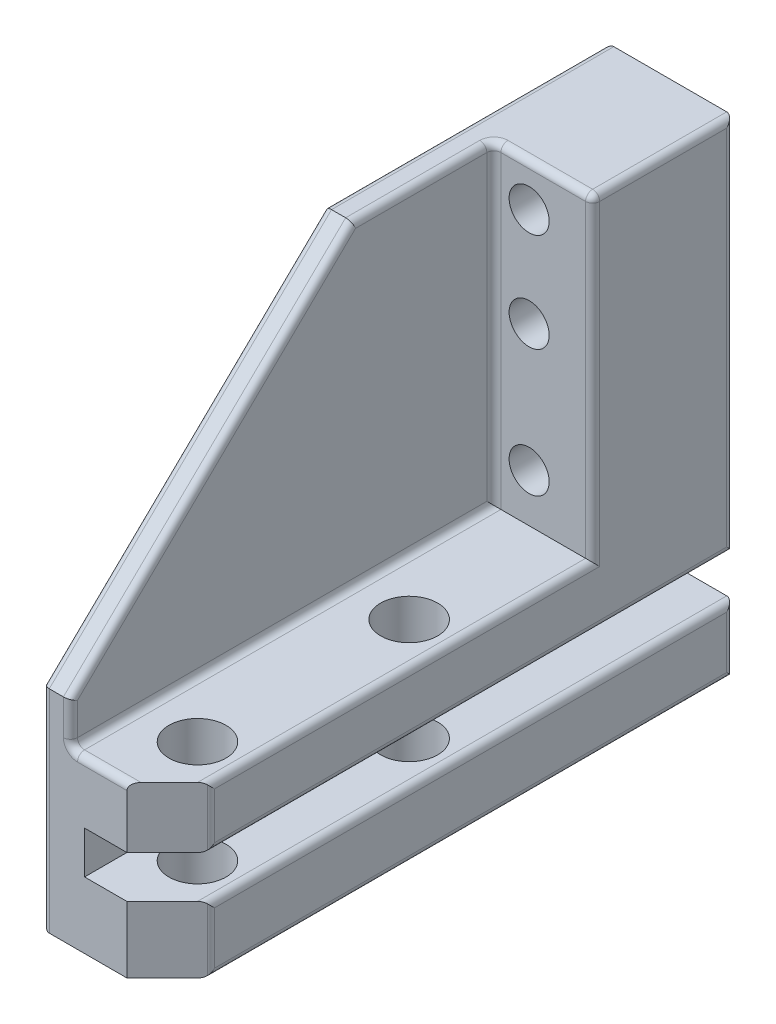
from build123d import *

# Parameters (mm, degrees)
SKETCH1_W           = 9
SKETCH1_H           = 34.4
SKETCH1_R           = 1.42
BOSS_EXTRUDE1_DEPTH = 40
SKETCH1_3_R         = 1.42
CUT_EXTRUDE1_DEPTH  = 10
SKETCH2_W           = 40
SKETCH2_H           = 3
CUT_EXTRUDE2_DEPTH  = 6
CUT_EXTRUDE3_DEPTH  = 9
CUT_EXTRUDE6_DEPTH  = 7
SKETCH6_R           = 2.0193
CUT_EXTRUDE5_DEPTH  = 20
FILLET2_R           = 0.5
CHAMFER4_SIZE       = 3
FILLET3_R           = 0.5


with BuildPart() as part:
    # Sketch1 → Boss-Extrude1 (new body)
    with BuildSketch(Plane.XY):
        with Locations((4.5, 17.2)):
            Rectangle(SKETCH1_W, SKETCH1_H)
        with Locations((4.5, 15.4)):
            Circle(SKETCH1_R, mode=Mode.SUBTRACT)
        with Locations((4.5, 24.4)):
            Circle(SKETCH1_R, mode=Mode.SUBTRACT)
        with Locations((4.5, 24.4)):
            Circle(SKETCH1_R)
        with Locations((4.5, 15.4)):
            Circle(SKETCH1_R)
        with Locations((4.5, 31.4)):
            Circle(SKETCH1_R)
    extrude(amount=BOSS_EXTRUDE1_DEPTH)

    # Sketch1_3 → Cut-Extrude1 (cut)
    with BuildSketch(Plane.XY):
        with Locations((4.5, 24.4)):
            Circle(SKETCH1_3_R)
        with Locations((4.5, 31.4)):
            Circle(SKETCH1_3_R)
        with Locations((4.5, 15.4)):
            Circle(SKETCH1_3_R)
    extrude(amount=CUT_EXTRUDE1_DEPTH, mode=Mode.SUBTRACT)

    # Sketch2 → Cut-Extrude2 (cut)
    with BuildSketch(Plane(origin=(9, 0, 0), x_dir=(0, 0, -1), z_dir=(1, 0, 0))):
        with Locations((-20, 6.2)):
            Rectangle(SKETCH2_W, SKETCH2_H)
    extrude(amount=-CUT_EXTRUDE2_DEPTH, mode=Mode.SUBTRACT)

    # Sketch3 → Cut-Extrude3 (cut)
    with BuildSketch(Plane(origin=(9, 0, 0), x_dir=(0, 0, -1), z_dir=(1, 0, 0))):
        Polygon((-20, 34.4), (-40, 15), (-48.379363257, 51.913157268), align=None)
    extrude(amount=-CUT_EXTRUDE3_DEPTH, mode=Mode.SUBTRACT)

    # Sketch5 → Cut-Extrude6 (cut)
    with BuildSketch(Plane.ZY.offset(-9)):
        Polygon((20, 34.4), (10, 34.4), (10, 12), (40, 12), (40, 15), align=None)
    extrude(amount=CUT_EXTRUDE6_DEPTH, mode=Mode.SUBTRACT)

    # Sketch6 → Cut-Extrude5 (cut)
    with BuildSketch(Plane.XZ):
        with Locations((6, 35)):
            Circle(SKETCH6_R)
        with Locations((6, 20)):
            Circle(SKETCH6_R)
    extrude(amount=-CUT_EXTRUDE5_DEPTH, mode=Mode.SUBTRACT)

    # Fillet2
    fillet2_edges = [part.edges().sort_by_distance(p)[0] for p in [
        (0, 0, 20),
        (0, 7.5, 40),
        (0, 34.4, 10),
        (0, 24.7, 30),
        (0, 17.2, 0),
    ]]
    fillet(fillet2_edges, radius=FILLET2_R)

    # Chamfer4
    chamfer4_edges = [part.edges().sort_by_distance(p)[0] for p in [
        (9, 2.35, 40),
        (9, 9.85, 40),
    ]]
    chamfer(chamfer4_edges, length=CHAMFER4_SIZE)

    # Fillet3
    fillet3_edges = [part.edges().sort_by_distance(p)[0] for p in [
        (9, 4.7, 18.5),
        (9, 0, 18.5),
        (9, 2.35, 37),
        (9, 9.85, 37),
        (9, 21.05, 0),
        (9, 7.7, 18.5),
        (9, 34.4, 5),
        (9, 12, 23.5),
        (2, 13.5, 40),
        (4, 12, 40),
        (2, 24.7, 30),
        (2, 34.4, 15),
        (9, 23.2, 10),
        (5.5, 34.4, 10),
        (2, 12, 25),
        (2, 23.2, 10),
        (9, 2.35, 0),
    ]]
    fillet(fillet3_edges, radius=FILLET3_R)


solid = part.part
